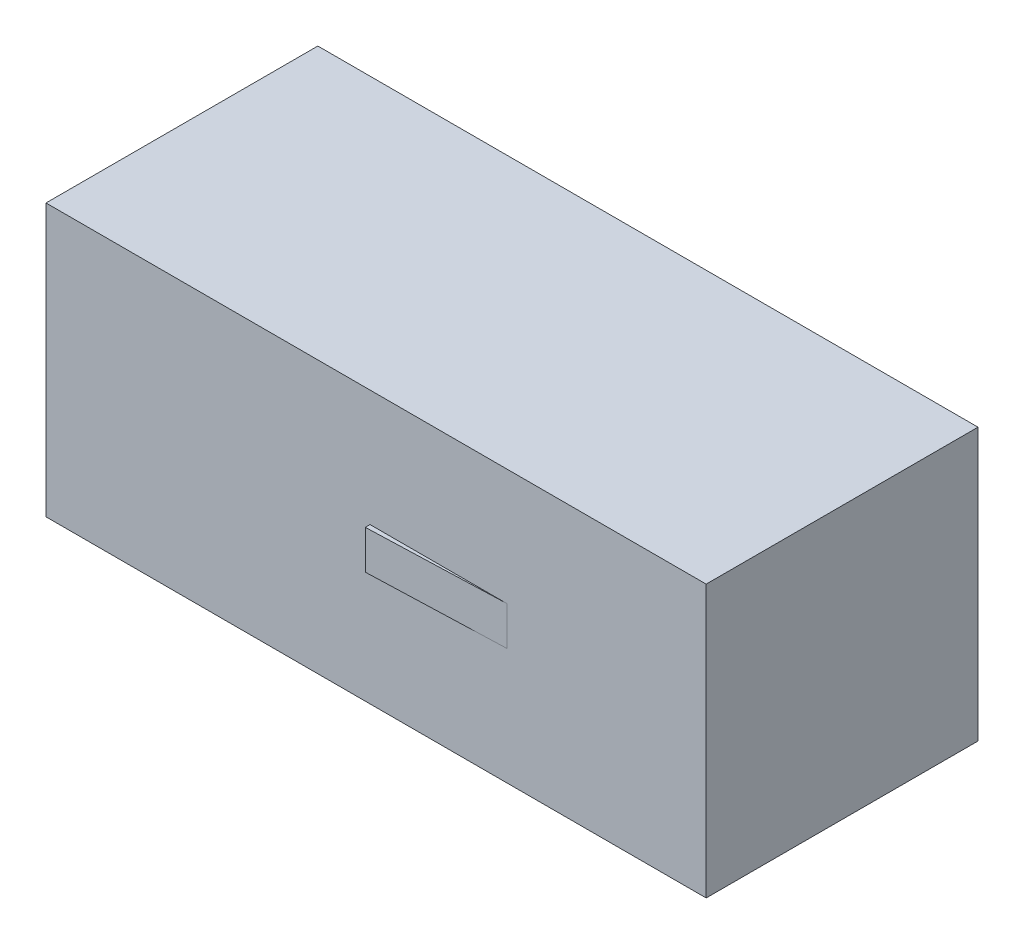
from build123d import *

# Parameters (mm, degrees)
SKETCH_1_W      = 170
SKETCH_1_H      = 70
EXTRUDE_1_DEPTH = 35
EXTRUDE_START   = -35
EXTRUDE_2_DEPTH = 5


with BuildPart() as part:
    # Эскиз1 → Бобышка-Вытянуть1 (new body, symmetric)
    with BuildSketch(Plane.XY):
        Rectangle(SKETCH_1_W, SKETCH_1_H)
    extrude(amount=EXTRUDE_1_DEPTH, both=True)

    # Эскиз2 → Бобышка-Вытянуть2 (add, symmetric)
    with BuildSketch(Plane.XZ.offset(35).offset(EXTRUDE_START)):
        Polygon((33.713551402, 35), (-1.569013743, 35), (-1.526040465, 36.230593665), align=None)
    extrude(amount=EXTRUDE_2_DEPTH, both=True)


solid = part.part
